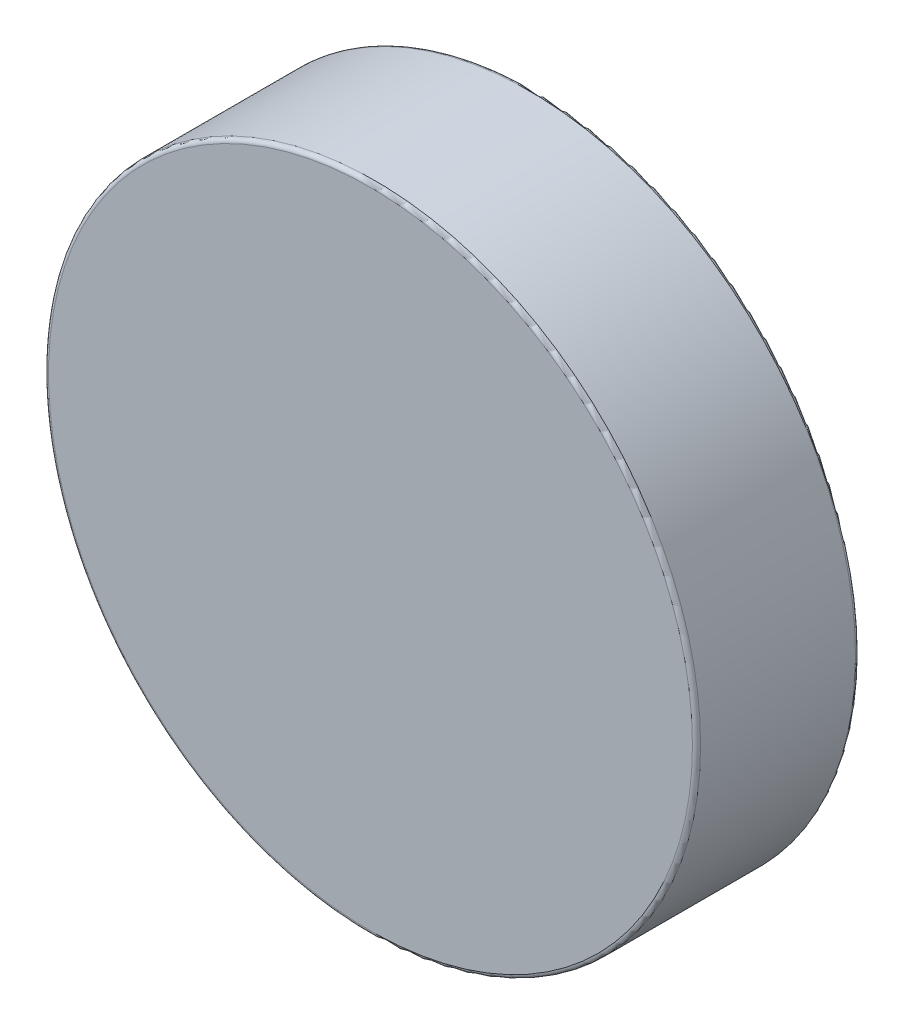
from build123d import *

# Parameters (mm, degrees)
SKETCH3_R                = 3.175
BOSS_EXTRUDE1_DEPTH      = 0.79375
BOSS_EXTRUDE1_DEPTH_BACK = 0.79375
FILLET1_R                = 0.0396875


with BuildPart() as part:
    # Sketch3 → Boss-Extrude1 (new body, two sides)
    with BuildSketch(Plane.XY) as boss_extrude1_sk:
        Circle(SKETCH3_R)
    extrude(amount=BOSS_EXTRUDE1_DEPTH)
    extrude(boss_extrude1_sk.sketch, amount=-BOSS_EXTRUDE1_DEPTH_BACK)

    # Fillet1
    fillet1_edges = [part.edges().sort_by_distance(p)[0] for p in [
        (-3.175, 0, -0.79375),
        (-3.175, 0, 0.79375),
    ]]
    fillet(fillet1_edges, radius=FILLET1_R)


solid = part.part
